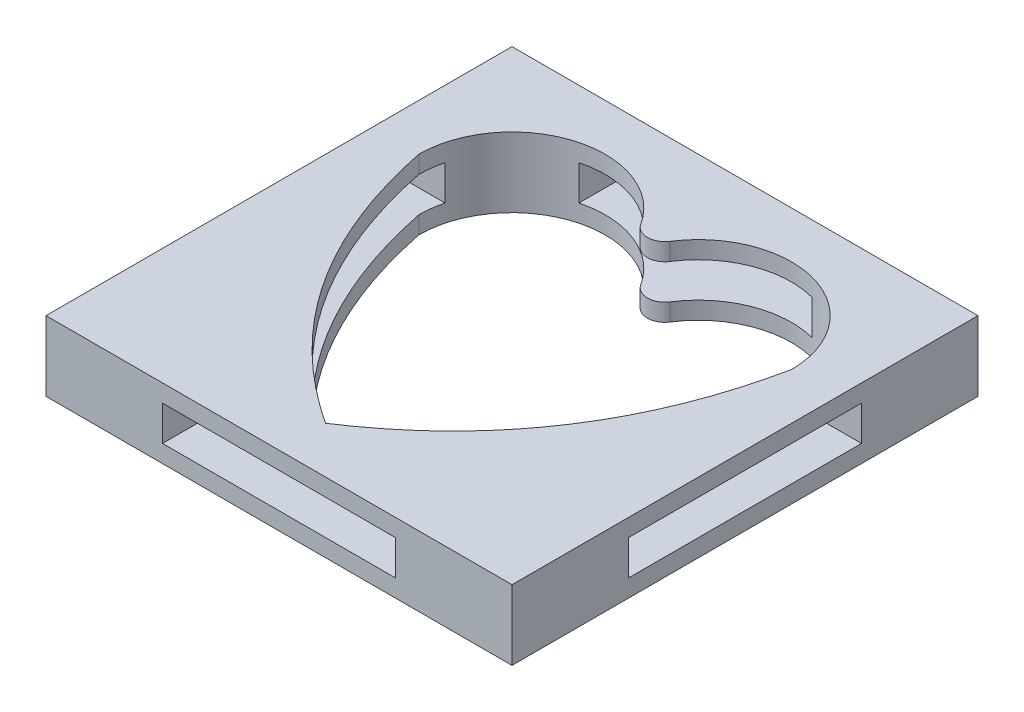
from build123d import *

# Parameters (mm, degrees)
SKETCH1_W           = 20
SKETCH1_H           = 20
BOSS_EXTRUDE1_DEPTH = 3
SKETCH2_W           = 10
SKETCH2_H           = 1.5
CUT_EXTRUDE1_DEPTH  = 21.0000001
SKETCH3_W           = 10
SKETCH3_H           = 1.5
CUT_EXTRUDE2_DEPTH  = 21.0000001


with BuildPart() as part:
    # Sketch1 → Boss-Extrude1 (new body)
    with BuildSketch(Plane(origin=(0, 0, 0), x_dir=(1, 0, 0), z_dir=(0, 1, 0))):
        Rectangle(SKETCH1_W, SKETCH1_H)
        with BuildLine():
            ThreePointArc((-0.631578947, 6.157252793), (-5.123902974, 7.83885948), (-8, 4))
            add(Edge.make_bspline(
                [(-8, 4), (-6.403336947, -3.811544104), (0, -8)],
                knots=[0, 0, 0, 1, 1, 1], degree=2))
            add(Edge.make_bspline(
                [(8, 4), (6.403336947, -3.811544104), (0, -8)],
                knots=[0, 0, 0, 1, 1, 1], degree=2))
            ThreePointArc((8, 4), (5.123902974, 7.83885948), (0.631578947, 6.157252793))
            ThreePointArc((0.631578947, 6.157252793), (0, 5.811737691), (-0.631578947, 6.157252793))
        make_face(mode=Mode.SUBTRACT)
    extrude(amount=BOSS_EXTRUDE1_DEPTH)

    # Sketch2 → Cut-Extrude1 (cut, through all)
    with BuildSketch(Plane(origin=(10, 0, 0), x_dir=(0, 0, -1), z_dir=(1, 0, 0))):
        with Locations((0, 1.5)):
            Rectangle(SKETCH2_W, SKETCH2_H)
    extrude(amount=-CUT_EXTRUDE1_DEPTH, mode=Mode.SUBTRACT)

    # Sketch3 → Cut-Extrude2 (cut, through all)
    with BuildSketch(Plane.XY.offset(10)):
        with Locations((0, 1.5)):
            Rectangle(SKETCH3_W, SKETCH3_H)
    extrude(amount=-CUT_EXTRUDE2_DEPTH, mode=Mode.SUBTRACT)


solid = part.part
